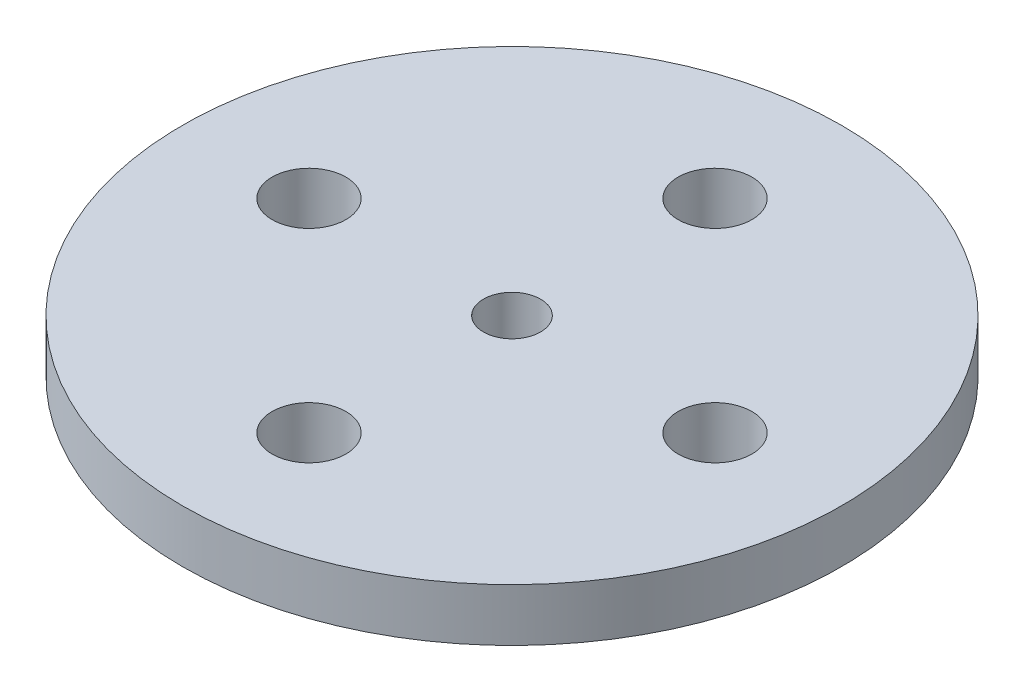
from build123d import *

# Parameters (mm, degrees)
SKETCH1_R           = 0.5
SKETCH1_R_2         = 1.375
BOSS_EXTRUDE1_DEPTH = 2
SKETCH4_R           = 4.6270037
SKETCH4_R_2         = 2.6270037
BOSS_EXTRUDE3_DEPTH = 2.5
CUT_EXTRUDE3_DEPTH  = 2.5
SKETCH6_R           = 15.875
SKETCH6_R_2         = 3.75
BOSS_EXTRUDE6_DEPTH = 2.54
SKETCH7_R           = 1.778
CUT_EXTRUDE4_DEPTH  = 2.54
CIRPATTERN1_COUNT   = 4


with BuildPart() as part:
    # Sketch1 → Boss-Extrude1 (new body)
    with BuildSketch(Plane(origin=(0, 0, 0), x_dir=(1, 0, 0), z_dir=(0, 1, 0))):
        with BuildLine():
            Line((-4, 4), (-2.467435953, 13.402193757))
            ThreePointArc((-2.467435953, 13.402193757), (0, 15.5), (2.467435953, 13.402193757))
            Line((2.467435953, 13.402193757), (4, 4))
            Line((4, 4), (12.448472752, 2.459445505))
            ThreePointArc((12.448472752, 2.459445505), (14.5, 0), (12.448472752, -2.459445505))
            Line((12.448472752, -2.459445505), (4, -4))
            Line((4, -4), (2.467435953, -13.402193757))
            ThreePointArc((2.467435953, -13.402193757), (0, -15.5), (-2.467435953, -13.402193757))
            Line((-2.467435953, -13.402193757), (-4, -4))
            Line((-4, -4), (-12.448472752, -2.459445505))
            ThreePointArc((-12.448472752, -2.459445505), (-14.5, 0), (-12.448472752, 2.459445505))
            Line((-12.448472752, 2.459445505), (-4, 4))
        make_face()
        with Locations((0, 12)):
            Circle(SKETCH1_R, mode=Mode.SUBTRACT)
        with Locations((0, 9.5)):
            Circle(SKETCH1_R, mode=Mode.SUBTRACT)
        with Locations((0, 7.5)):
            Circle(SKETCH1_R, mode=Mode.SUBTRACT)
        with Locations((12, 0)):
            Circle(SKETCH1_R, mode=Mode.SUBTRACT)
        with Locations((9.5, 0)):
            Circle(SKETCH1_R, mode=Mode.SUBTRACT)
        with Locations((7.5, 0)):
            Circle(SKETCH1_R, mode=Mode.SUBTRACT)
        with Locations((0, -12)):
            Circle(SKETCH1_R, mode=Mode.SUBTRACT)
        with Locations((0, -9.5)):
            Circle(SKETCH1_R, mode=Mode.SUBTRACT)
        with Locations((0, -7.5)):
            Circle(SKETCH1_R, mode=Mode.SUBTRACT)
        with Locations((-12, 0)):
            Circle(SKETCH1_R, mode=Mode.SUBTRACT)
        with Locations((-9.5, 0)):
            Circle(SKETCH1_R, mode=Mode.SUBTRACT)
        with Locations((-7.5, 0)):
            Circle(SKETCH1_R, mode=Mode.SUBTRACT)
        Circle(SKETCH1_R_2, mode=Mode.SUBTRACT)
    extrude(amount=BOSS_EXTRUDE1_DEPTH)

    # Sketch4 → Boss-Extrude3 (add)
    with BuildSketch(Plane.XZ):
        Circle(SKETCH4_R)
        Circle(SKETCH4_R_2, mode=Mode.SUBTRACT)
    extrude(amount=BOSS_EXTRUDE3_DEPTH)

    # Sketch5 → Cut-Extrude3 (cut)
    with BuildSketch(Plane.XZ.offset(2.5)):
        with BuildLine():
            Line((0.282820055, 2.611735296), (0, 3.101594))
            Line((0, 3.101594), (-0.282820055, 2.611735296))
            ThreePointArc((-0.282820055, 2.611735296), (0, 2.6270037), (0.282820055, 2.611735296))
        make_face()
        with BuildLine():
            ThreePointArc((-1.076048447, 2.396511669), (-0.811788788, 2.498428987), (-0.538092735, 2.571304075))
            Line((-0.538092735, 2.571304075), (-0.958445256, 2.949791185))
            Line((-0.958445256, 2.949791185), (-1.076048447, 2.396511669))
        make_face()
        with BuildLine():
            Line((0.958445256, 2.949791185), (0.538092735, 2.571304075))
            ThreePointArc((0.538092735, 2.571304075), (0.811788788, 2.498428987), (1.076048447, 2.396511669))
            Line((1.076048447, 2.396511669), (0.958445256, 2.949791185))
        make_face()
        with BuildLine():
            ThreePointArc((-1.76394572, 1.946700782), (-1.544114033, 2.125290638), (-1.306333259, 2.279175696))
            Line((-1.306333259, 2.279175696), (-1.823071212, 2.509242256))
            Line((-1.823071212, 2.509242256), (-1.76394572, 1.946700782))
        make_face()
        with BuildLine():
            Line((1.823071212, 2.509242256), (1.306333259, 2.279175696))
            ThreePointArc((1.306333259, 2.279175696), (1.544114033, 2.125290638), (1.76394572, 1.946700782))
            Line((1.76394572, 1.946700782), (1.823071212, 2.509242256))
        make_face()
        with BuildLine():
            ThreePointArc((-2.279175696, 1.306333259), (-2.125290638, 1.544114033), (-1.946700782, 1.76394572))
            Line((-1.946700782, 1.76394572), (-2.509242256, 1.823071212))
            Line((-2.509242256, 1.823071212), (-2.279175696, 1.306333259))
        make_face()
        with BuildLine():
            Line((2.509242256, 1.823071212), (1.946700782, 1.76394572))
            ThreePointArc((1.946700782, 1.76394572), (2.125290638, 1.544114033), (2.279175696, 1.306333259))
            Line((2.279175696, 1.306333259), (2.509242256, 1.823071212))
        make_face()
        with BuildLine():
            ThreePointArc((-2.571304075, 0.538092735), (-2.498428987, 0.811788788), (-2.396511669, 1.076048447))
            Line((-2.396511669, 1.076048447), (-2.949791185, 0.958445256))
            Line((-2.949791185, 0.958445256), (-2.571304075, 0.538092735))
        make_face()
        with BuildLine():
            Line((2.949791185, 0.958445256), (2.396511669, 1.076048447))
            ThreePointArc((2.396511669, 1.076048447), (2.498428987, 0.811788788), (2.571304075, 0.538092735))
            Line((2.571304075, 0.538092735), (2.949791185, 0.958445256))
        make_face()
        with BuildLine():
            ThreePointArc((-2.611735296, -0.282820055), (-2.6270037, 0), (-2.611735296, 0.282820055))
            Line((-2.611735296, 0.282820055), (-3.101594, 0))
            Line((-3.101594, 0), (-2.611735296, -0.282820055))
        make_face()
        with BuildLine():
            Line((3.101594, 0), (2.611735296, 0.282820055))
            ThreePointArc((2.611735296, 0.282820055), (2.6270037, 0), (2.611735296, -0.282820055))
            Line((2.611735296, -0.282820055), (3.101594, 0))
        make_face()
        with BuildLine():
            ThreePointArc((-2.396511669, -1.076048447), (-2.498428987, -0.811788788), (-2.571304075, -0.538092735))
            Line((-2.571304075, -0.538092735), (-2.949791185, -0.958445256))
            Line((-2.949791185, -0.958445256), (-2.396511669, -1.076048447))
        make_face()
        with BuildLine():
            Line((2.949791185, -0.958445256), (2.571304075, -0.538092735))
            ThreePointArc((2.571304075, -0.538092735), (2.498428987, -0.811788788), (2.396511669, -1.076048447))
            Line((2.396511669, -1.076048447), (2.949791185, -0.958445256))
        make_face()
        with BuildLine():
            ThreePointArc((-1.946700782, -1.76394572), (-2.125290638, -1.544114033), (-2.279175696, -1.306333259))
            Line((-2.279175696, -1.306333259), (-2.509242256, -1.823071212))
            Line((-2.509242256, -1.823071212), (-1.946700782, -1.76394572))
        make_face()
        with BuildLine():
            Line((2.509242256, -1.823071212), (2.279175696, -1.306333259))
            ThreePointArc((2.279175696, -1.306333259), (2.125290638, -1.544114033), (1.946700782, -1.76394572))
            Line((1.946700782, -1.76394572), (2.509242256, -1.823071212))
        make_face()
        with BuildLine():
            ThreePointArc((-1.306333259, -2.279175696), (-1.544114033, -2.125290638), (-1.76394572, -1.946700782))
            Line((-1.76394572, -1.946700782), (-1.823071212, -2.509242256))
            Line((-1.823071212, -2.509242256), (-1.306333259, -2.279175696))
        make_face()
        with BuildLine():
            Line((1.823071212, -2.509242256), (1.76394572, -1.946700782))
            ThreePointArc((1.76394572, -1.946700782), (1.544114033, -2.125290638), (1.306333259, -2.279175696))
            Line((1.306333259, -2.279175696), (1.823071212, -2.509242256))
        make_face()
        with BuildLine():
            ThreePointArc((-0.538092735, -2.571304075), (-0.811788788, -2.498428987), (-1.076048447, -2.396511669))
            Line((-1.076048447, -2.396511669), (-0.958445256, -2.949791185))
            Line((-0.958445256, -2.949791185), (-0.538092735, -2.571304075))
        make_face()
        with BuildLine():
            Line((0.958445256, -2.949791185), (1.076048447, -2.396511669))
            ThreePointArc((1.076048447, -2.396511669), (0.811788788, -2.498428987), (0.538092735, -2.571304075))
            Line((0.538092735, -2.571304075), (0.958445256, -2.949791185))
        make_face()
        with BuildLine():
            ThreePointArc((0.282820055, -2.611735296), (0, -2.6270037), (-0.282820055, -2.611735296))
            Line((-0.282820055, -2.611735296), (0, -3.101594))
            Line((0, -3.101594), (0.282820055, -2.611735296))
        make_face()
    extrude(amount=-CUT_EXTRUDE3_DEPTH, mode=Mode.SUBTRACT)

    # Sketch6 → Boss-Extrude6 (add)
    with BuildSketch(Plane(origin=(0, 2, 0), x_dir=(1, 0, 0), z_dir=(0, 1, 0))):
        Circle(SKETCH6_R)
        Circle(SKETCH6_R_2, mode=Mode.SUBTRACT)
    extrude(amount=-BOSS_EXTRUDE6_DEPTH)

    # Sketch7 → Cut-Extrude4 (cut)
    with BuildSketch(Plane(origin=(0, 2, 0), x_dir=(1, 0, 0), z_dir=(0, 1, 0))):
        with Locations((0, 9.779)):
            Circle(SKETCH7_R)
    cut_extrude4 = extrude(amount=-CUT_EXTRUDE4_DEPTH, mode=Mode.SUBTRACT)

    # CirPattern1: Cut-Extrude4 ×4 about axis
    cirpattern1_axis = Axis((0, 0, 0), (0, 1, 0))
    for i in range(1, CIRPATTERN1_COUNT):
        add(cut_extrude4.rotate(cirpattern1_axis, i * 360 / CIRPATTERN1_COUNT), mode=Mode.SUBTRACT)


solid = part.part
